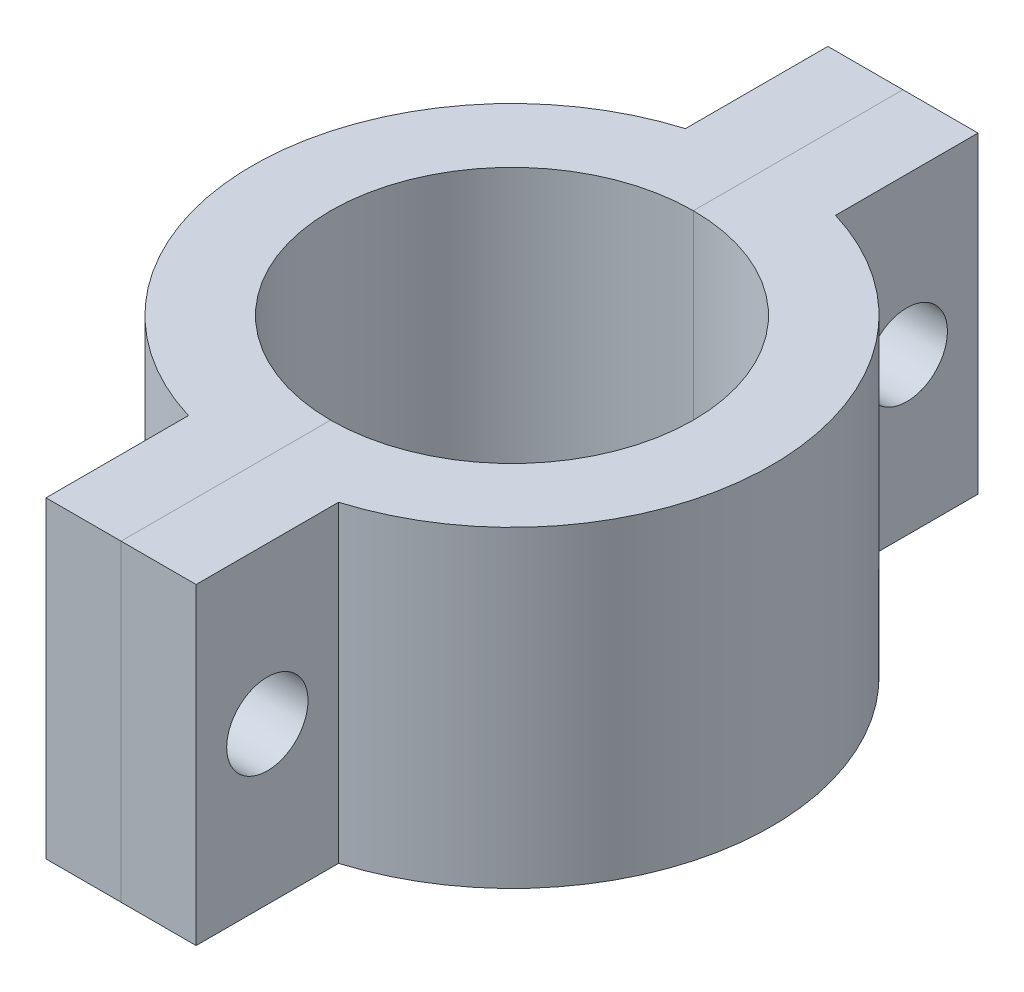
from build123d import *

# Parameters (mm, degrees)
BOSS_EXTRUDE2_DEPTH = 25.4
CUT_EXTRUDE1_REACH  = 29.178
SKETCH2_R           = 3.302
SKETCH3_R           = 4.7625
CUT_EXTRUDE2_DEPTH  = 5.08


with BuildPart() as part:
    # Sketch1 → Boss-Extrude2 (new body)
    with BuildSketch(Plane(origin=(0, 0, 0), x_dir=(1, 0, 0), z_dir=(0, 1, 0))):
        with BuildLine():
            Line((-6.096, 13.411584843), (-6.096, 20.181414916))
            ThreePointArc((-6.096, 20.181414916), (-21.082, 0), (-6.096, -20.181414916))
            Line((-6.096, -20.181414916), (-6.096, -13.411584843))
            ThreePointArc((-6.096, -13.411584843), (-14.732, 0), (-6.096, 13.411584843))
        make_face()
        with BuildLine():
            ThreePointArc((6.096, -20.181414916), (0, -21.082), (-6.096, -20.181414916))
            Line((-6.096, -20.181414916), (-6.096, -31.75))
            Line((-6.096, -31.75), (6.096, -31.75))
            Line((6.096, -31.75), (6.096, -20.181414916))
        make_face()
        with BuildLine():
            ThreePointArc((21.082, 0), (16.925817499, 12.568509299), (6.096, 20.181414916))
            Line((6.096, 20.181414916), (6.096, 13.411584843))
            ThreePointArc((6.096, 13.411584843), (12.386244306, 7.975761782), (14.732, 0))
            ThreePointArc((14.732, 0), (12.386244306, -7.975761782), (6.096, -13.411584843))
            Line((6.096, -13.411584843), (6.096, -20.181414916))
            ThreePointArc((6.096, -20.181414916), (16.925817499, -12.568509299), (21.082, 0))
        make_face()
        with BuildLine():
            ThreePointArc((6.096, 20.181414916), (0, 21.082), (-6.096, 20.181414916))
            Line((-6.096, 20.181414916), (-6.096, 13.411584843))
            ThreePointArc((-6.096, 13.411584843), (0, 14.732), (6.096, 13.411584843))
            Line((6.096, 13.411584843), (6.096, 20.181414916))
        make_face()
        with BuildLine():
            Line((-6.096, -13.411584843), (-6.096, -20.181414916))
            ThreePointArc((-6.096, -20.181414916), (0, -21.082), (6.096, -20.181414916))
            Line((6.096, -20.181414916), (6.096, -13.411584843))
            ThreePointArc((6.096, -13.411584843), (0, -14.732), (-6.096, -13.411584843))
        make_face()
        with BuildLine():
            Line((6.096, 31.75), (-6.096, 31.75))
            Line((-6.096, 31.75), (-6.096, 20.181414916))
            ThreePointArc((-6.096, 20.181414916), (0, 21.082), (6.096, 20.181414916))
            Line((6.096, 20.181414916), (6.096, 31.75))
        make_face()
    extrude(amount=BOSS_EXTRUDE2_DEPTH)

    # Sketch2 → Cut-Extrude1 (cut, up to next)
    with BuildSketch(Plane.ZY.offset(6.096), mode=Mode.PRIVATE) as cut_extrude1_sk1:
        with Locations((-25.965707458, 12.7)):
            Circle(SKETCH2_R)
    cut_extrude1_tool1 = extrude(cut_extrude1_sk1.sketch, amount=-CUT_EXTRUDE1_REACH, mode=Mode.PRIVATE) & part.part
    add(cut_extrude1_tool1.solids().sort_by_distance((-6.096, 12.7, -25.965707))[0], mode=Mode.SUBTRACT)
    # Sketch2 → Cut-Extrude1 (cut, up to next)
    with BuildSketch(Plane.ZY.offset(6.096), mode=Mode.PRIVATE) as cut_extrude1_sk2:
        with Locations((25.965707458, 12.7)):
            Circle(SKETCH2_R)
    cut_extrude1_tool2 = extrude(cut_extrude1_sk2.sketch, amount=-CUT_EXTRUDE1_REACH, mode=Mode.PRIVATE) & part.part
    add(cut_extrude1_tool2.solids().sort_by_distance((-6.096, 12.7, 25.965707))[0], mode=Mode.SUBTRACT)

    # Sketch3 → Cut-Extrude2 (cut)
    with BuildSketch(Plane.ZY.offset(6.096)):
        with Locations((-25.965707458, 12.7)):
            Circle(SKETCH3_R)
        with Locations((25.965707458, 12.7)):
            Circle(SKETCH3_R)
    extrude(amount=-CUT_EXTRUDE2_DEPTH, mode=Mode.SUBTRACT)


with BuildPart() as body_2:
    # Split1: the piece on the far side of the plane
    add(part.part)
    split(bisect_by=Plane(origin=(0, 0, 0), x_dir=(0, 0, -1), z_dir=(-1, 0, 0)), keep=Keep.BOTTOM)


with BuildPart() as part_1:
    add(part.part)

    # Split1
    split(bisect_by=Plane(origin=(0, 0, 0), x_dir=(0, 0, -1), z_dir=(-1, 0, 0)), keep=Keep.TOP)


solid = Compound([body_2.part, part_1.part])
